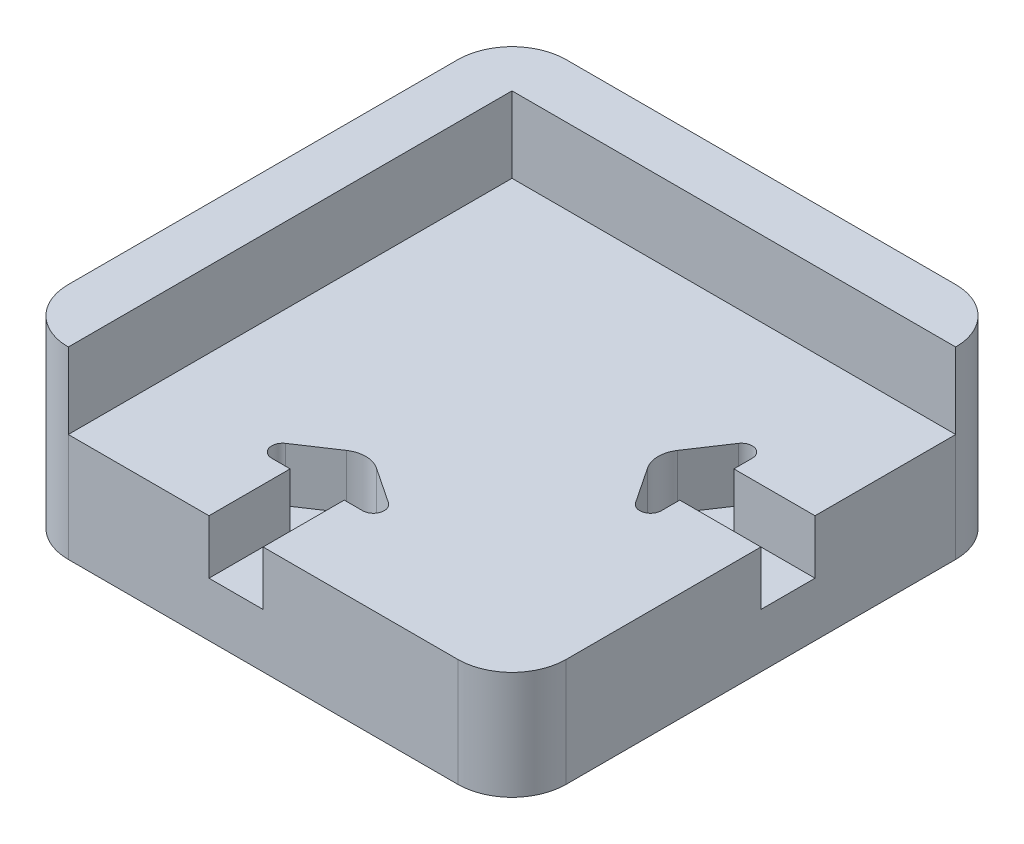
from build123d import *

# Parameters (mm, degrees)
SKETCH1_W           = 92
SKETCH1_H           = 92
BOSS_EXTRUDE1_DEPTH = 20
BOSS_EXTRUDE2_DEPTH = 34
FILLET1_R           = 10
CUT_EXTRUDE2_DEPTH  = 10
CUT_EXTRUDE3_DEPTH  = 10
FILLET2_R           = 5
FILLET3_R           = 2


with BuildPart() as part:
    # Sketch1 → Boss-Extrude1 (new body)
    with BuildSketch(Plane(origin=(0, 0, 0), x_dir=(1, 0, 0), z_dir=(0, 1, 0))):
        with Locations((10.533475027, -26.001062699)):
            Rectangle(SKETCH1_W, SKETCH1_H)
    extrude(amount=BOSS_EXTRUDE1_DEPTH)

    # Sketch1_3 → Boss-Extrude2 (add)
    with BuildSketch(Plane(origin=(0, 0, 0), x_dir=(1, 0, 0), z_dir=(0, 1, 0))):
        Polygon((-35.466524973, 19.998937301), (-35.466524973, -72.001062699), (-25.466524973, -72.001062699), (-25.466524973, 9.998937301), (56.533475027, 9.998937301), (56.533475027, 19.998937301), align=None)
    extrude(amount=BOSS_EXTRUDE2_DEPTH)

    # Fillet1
    fillet1_edges = [part.edges().sort_by_distance(p)[0] for p in [
        (56.533475027, 17, -19.998937301),
        (-35.466524973, 17, -19.998937301),
        (-35.466524973, 17, 72.001062699),
        (56.533475027, 10, 72.001062699),
    ]]
    fillet(fillet1_edges, radius=FILLET1_R)

    # Sketch5 → Cut-Extrude2 (cut)
    with BuildSketch(Plane(origin=(0, 20, 0), x_dir=(1, 0, 0), z_dir=(0, 1, 0))):
        Polygon((0.533475027, -72.001062699), (10.533475027, -72.001062699), (10.533475027, -57.001062699), (20.532072448, -57.001062699), (5.533475027, -47.001062699), (-9.466524973, -57.001062699), (0.533475027, -57.001062699), align=None)
    extrude(amount=-CUT_EXTRUDE2_DEPTH, mode=Mode.SUBTRACT)

    # Sketch6 → Cut-Extrude3 (cut)
    with BuildSketch(Plane(origin=(0, 20, 0), x_dir=(1, 0, 0), z_dir=(0, 1, 0))):
        Polygon((41.533475027, -26.001062699), (56.533475027, -26.001062699), (56.533475027, -16.001062699), (41.533475027, -16.001062699), (41.533475027, -6.001062699), (31.533475027, -21.001062699), (41.533475027, -36.001062699), align=None)
    extrude(amount=-CUT_EXTRUDE3_DEPTH, mode=Mode.SUBTRACT)

    # Fillet2
    fillet2_edges = [part.edges().sort_by_distance(p)[0] for p in [
        (31.533475027, 15, 21.001062699),
        (5.533475027, 15, 47.001062699),
    ]]
    fillet(fillet2_edges, radius=FILLET2_R)

    # Fillet3
    fillet3_edges = [part.edges().sort_by_distance(p)[0] for p in [
        (41.533475027, 15, 6.001062699),
        (41.533475027, 15, 36.001062699),
        (20.532072448, 15, 57.001062699),
        (-9.466524973, 15, 57.001062699),
    ]]
    fillet(fillet3_edges, radius=FILLET3_R)


solid = part.part
